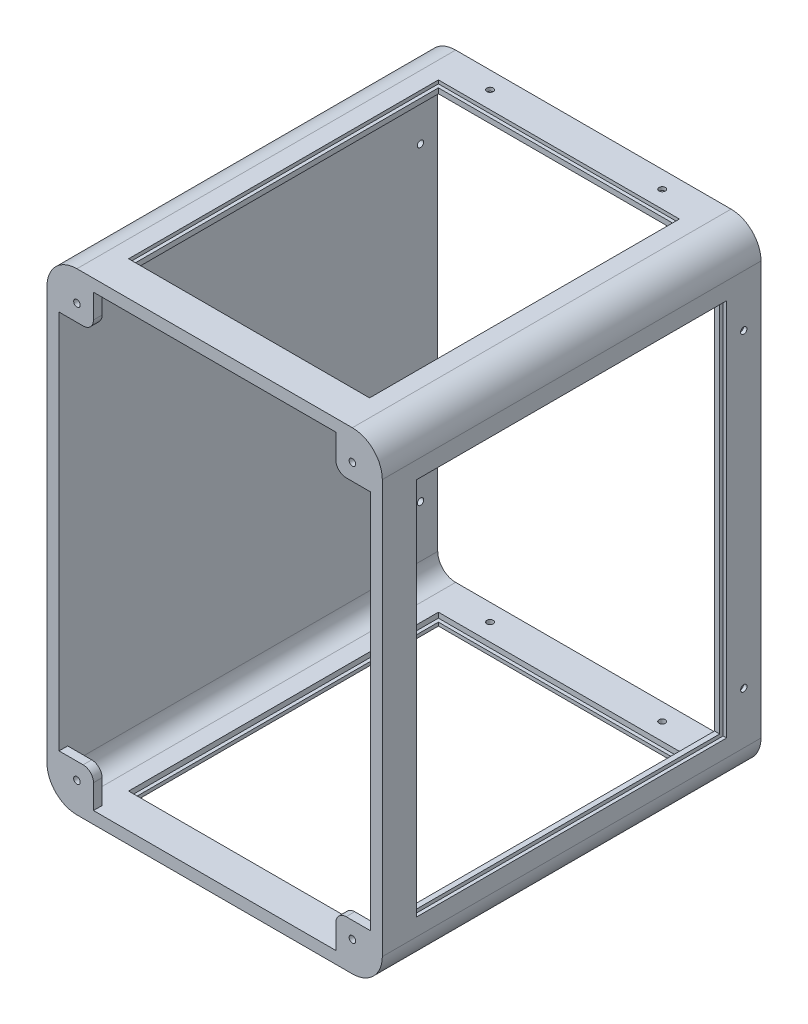
from build123d import *

# Parameters (mm, degrees)
SKETCH3_W               = 110
SKETCH3_H               = 3.5
SKETCH4_R               = 0.95
BOSS_EXTRUDE2_DEPTH     = 2.5
MIRROR4_COPY_1_SKETCH_R = 0.95
MIRROR4_COPY_1_DEPTH    = 2.5
CUT_EXTRUDE1_REACH      = 99.4
SKETCH5_W               = 90
SKETCH5_H               = 110
SKETCH6_W               = 70
SKETCH6_H               = 90
CUT_EXTRUDE2_DEPTH      = 138.4
SKETCH7_R               = 0.925
CUT_EXTRUDE3_DEPTH      = 98.4
SKETCH9_R               = 0.925
CUT_EXTRUDE5_DEPTH      = 138.4
SKETCH8_W               = 76
SKETCH8_H               = 1
SKETCH8_W_2             = 1
SKETCH8_H_2             = 116
CUT_EXTRUDE4_DEPTH      = 103


with BuildPart() as part:
    # Sweep1: sweep along a path in Sketch1
    with BuildLine(Plane.XY) as sweep1_path:
        Line((45, -60), (45, 60))
        ThreePointArc((45, 60), (43.535533906, 63.535533906), (40, 65))
        Line((40, 65), (-40, 65))
        ThreePointArc((-40, 65), (-43.535533906, 63.535533906), (-45, 60))
        Line((-45, 60), (-45, -60))
        ThreePointArc((-45, -60), (-43.535533906, -63.535533906), (-40, -65))
        Line((-40, -65), (40, -65))
        ThreePointArc((40, -65), (43.535533906, -63.535533906), (45, -60))
    # Sketch3 → Sweep1 (sweep)
    with BuildSketch(Plane(origin=(40, 65, 0), x_dir=(0, 0, 1), z_dir=(-1, 0, 0))):
        with Locations((-52.5, 1.95)):
            Rectangle(SKETCH3_W, SKETCH3_H)
    sweep(path=sweep1_path.line)

    # Sketch4 → Boss-Extrude2 (add)
    with BuildSketch(Plane.XY.offset(2.5)):
        with BuildLine():
            Line((35.2, -65.2), (40, -65.2))
            ThreePointArc((40, -65.2), (43.676955262, -63.676955262), (45.2, -60))
            Line((45.2, -60), (45.2, -55.2))
            Line((45.2, -55.2), (38.2, -55.2))
            ThreePointArc((38.2, -55.2), (36.078679656, -56.078679656), (35.2, -58.2))
            Line((35.2, -58.2), (35.2, -65.2))
        make_face()
        with Locations((40, -60)):
            Circle(SKETCH4_R, mode=Mode.SUBTRACT)
    boss_extrude2 = extrude(amount=-BOSS_EXTRUDE2_DEPTH)

    # Mirror3: Boss-Extrude2 across plane
    add(boss_extrude2.mirror(Plane(origin=(0, 0, 0), x_dir=(0, 0, 1), z_dir=(1, 0, 0))))

    # Mirror4: Boss-Extrude2 across plane
    add(boss_extrude2.mirror(Plane.ZX))

    # Mirror4 copy 1 sketch → Mirror4 copy 1 (add)
    with BuildSketch(Plane(origin=(0, 0, 2.5), x_dir=(-1, 0, 0), z_dir=(0, 0, 1))):
        with BuildLine():
            Line((35.2, -65.2), (40, -65.2))
            ThreePointArc((40, -65.2), (43.676955262, -63.676955262), (45.2, -60))
            Line((45.2, -60), (45.2, -55.2))
            Line((45.2, -55.2), (38.2, -55.2))
            ThreePointArc((38.2, -55.2), (36.078679656, -56.078679656), (35.2, -58.2))
            Line((35.2, -58.2), (35.2, -65.2))
        make_face()
        with Locations((40, -60)):
            Circle(MIRROR4_COPY_1_SKETCH_R, mode=Mode.SUBTRACT)
    extrude(amount=-MIRROR4_COPY_1_DEPTH)

    # Sketch5 → Cut-Extrude1 (cut, up to next)
    with BuildSketch(Plane(origin=(48.7, 0, 0), x_dir=(0, 0, -1), z_dir=(1, 0, 0)), mode=Mode.PRIVATE) as cut_extrude1_sk1:
        with Locations((52.5, 0)):
            Rectangle(SKETCH5_W, SKETCH5_H)
    cut_extrude1_tool1 = extrude(cut_extrude1_sk1.sketch, amount=-CUT_EXTRUDE1_REACH, mode=Mode.PRIVATE) & part.part
    add(cut_extrude1_tool1.solids().sort_by_distance((48.7, 0, -52.5))[0], mode=Mode.SUBTRACT)

    # Sketch6 → Cut-Extrude2 (cut, through all)
    with BuildSketch(Plane(origin=(0, 68.7, 0), x_dir=(1, 0, 0), z_dir=(0, 1, 0))):
        with Locations((0, 52.5)):
            Rectangle(SKETCH6_W, SKETCH6_H)
    extrude(amount=-CUT_EXTRUDE2_DEPTH, mode=Mode.SUBTRACT)

    # Sketch7 → Cut-Extrude3 (cut, through all)
    with BuildSketch(Plane(origin=(48.7, 0, 0), x_dir=(0, 0, -1), z_dir=(1, 0, 0))):
        with Locations((102.5, 45)):
            Circle(SKETCH7_R)
        with Locations((102.5, -45)):
            Circle(SKETCH7_R)
    extrude(amount=-CUT_EXTRUDE3_DEPTH, mode=Mode.SUBTRACT)

    # Sketch9 → Cut-Extrude5 (cut, through all)
    with BuildSketch(Plane(origin=(0, 68.7, 0), x_dir=(1, 0, 0), z_dir=(0, 1, 0))):
        with Locations((-25, 102.5)):
            Circle(SKETCH9_R)
        with Locations((25, 102.5)):
            Circle(SKETCH9_R)
    extrude(amount=-CUT_EXTRUDE5_DEPTH, mode=Mode.SUBTRACT)

    # Sketch8 → Cut-Extrude4 (cut)
    with BuildSketch(Plane(origin=(0, 0, -107.5), x_dir=(-1, 0, 0), z_dir=(0, 0, -1))):
        with Locations((0, 67.2)):
            Rectangle(SKETCH8_W, SKETCH8_H)
        with Locations((-47.2, 0)):
            Rectangle(SKETCH8_W_2, SKETCH8_H_2)
        with Locations((0, -67.2)):
            Rectangle(SKETCH8_W, SKETCH8_H)
    extrude(amount=-CUT_EXTRUDE4_DEPTH, mode=Mode.SUBTRACT)


solid = part.part
